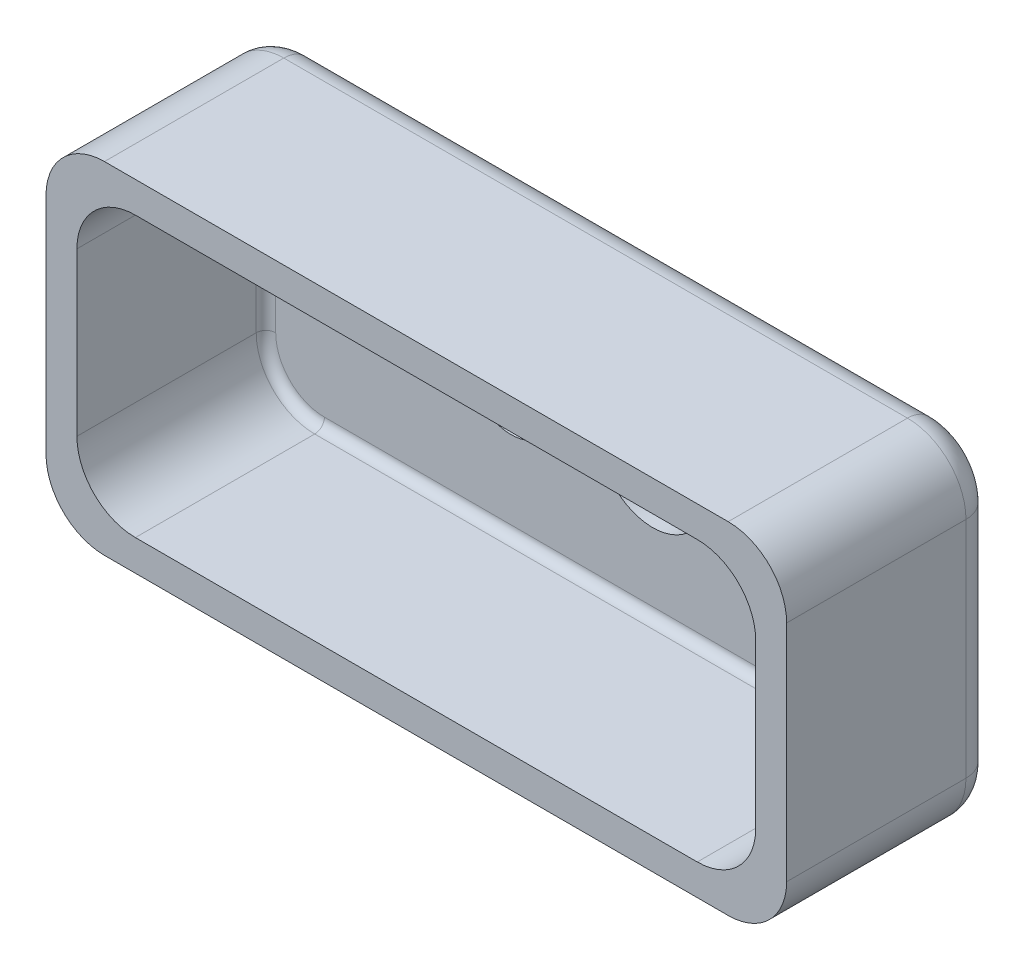
from build123d import *

# Parameters (mm, degrees)
SKETCH1_W                = 760
SKETCH1_H                = 350
BOSS_EXTRUDE1_DEPTH      = 38
SKETCH2_R                = 65
SKETCH2_R_2              = 55
SKETCH2_R_3              = 45
CUT_EXTRUDE1_DEPTH       = 473.628796964
CUT_EXTRUDE3_DEPTH       = 473.628796964
SKETCH5_R                = 75
SKETCH5_R_2              = 3
SKETCH5_R_3              = 70
SKETCH5_R_4              = 40
CUT_EXTRUDE7_DEPTH       = 7
SKETCH7_R                = 3
CUT_EXTRUDE8_DEPTH       = 473.628796964
SKETCH8_W                = 760
SKETCH8_H                = 350
CUT_EXTRUDE9_DEPTH       = 18
SKETCH9_OUTSIDE_W        = 929.392
SKETCH9_OUTSIDE_H        = 519.392
CUT_EXTRUDE10_DEPTH      = 472.523042618
BOSS_EXTRUDE2_DEPTH      = 194
FILLET1_R                = 10
SKETCH12_R               = 40
SKETCH12_R_2             = 20
SKETCH12_R_3             = 3
BOSS_EXTRUDE4_DEPTH      = 7
BOSS_EXTRUDE4_DEPTH_BACK = 2
SKETCH13_R               = 3
BOSS_EXTRUDE8_DEPTH      = 20
SKETCH11_R               = 80
SKETCH11_R_2             = 3
CUT_EXTRUDE11_DEPTH      = 7
SKETCH15_R               = 3
CUT_EXTRUDE12_DEPTH      = 518.42630366
FILLET2_R                = 30


with BuildPart() as part:
    # Sketch1 → Boss-Extrude1 (new body)
    with BuildSketch(Plane.XY):
        with Locations((42.843137255, 32.696078431)):
            Rectangle(SKETCH1_W, SKETCH1_H)
    extrude(amount=BOSS_EXTRUDE1_DEPTH)

    # Sketch2 → Cut-Extrude1 (cut, through all)
    with BuildSketch(Plane.XY.offset(38)):
        with Locations((245.403137255, 24.656078431)):
            Circle(SKETCH2_R)
        with Locations((91.403137255, 24.656078431)):
            Circle(SKETCH2_R_2)
        with Locations((-54.006862745, 24.656078431)):
            Circle(SKETCH2_R_3)
    extrude(amount=-CUT_EXTRUDE1_DEPTH, mode=Mode.SUBTRACT)

    # Sketch3 → Cut-Extrude3 (cut, through all)
    with BuildSketch(Plane.XY.offset(38)):
        with BuildLine():
            ThreePointArc((-211.086862745, 24.656078431), (-191.086862745, 4.656078431), (-171.086862745, 24.656078431))
            Line((-171.086862745, 24.656078431), (-191.086862745, 24.656078431))
            Line((-191.086862745, 24.656078431), (-211.086862745, 24.656078431))
        make_face()
        with BuildLine():
            Line((-191.086862745, 24.656078431), (-171.086862745, 24.656078431))
            ThreePointArc((-171.086862745, 24.656078431), (-191.086862745, 44.656078431), (-211.086862745, 24.656078431))
            Line((-211.086862745, 24.656078431), (-191.086862745, 24.656078431))
        make_face()
    extrude(amount=-CUT_EXTRUDE3_DEPTH, mode=Mode.SUBTRACT)

    # Sketch5 → Cut-Extrude7 (cut)
    with BuildSketch(Plane(origin=(0, 0, 0), x_dir=(-1, 0, 0), z_dir=(0, 0, -1))):
        with Locations((54.006862745, 24.656078431)):
            Circle(SKETCH5_R)
        with Locations((54.006862745, 84.656078431)):
            Circle(SKETCH5_R_2, mode=Mode.SUBTRACT)
        with Locations((105.968386972, -5.343921569)):
            Circle(SKETCH5_R_2, mode=Mode.SUBTRACT)
        with Locations((2.045338518, -5.343921569)):
            Circle(SKETCH5_R_2, mode=Mode.SUBTRACT)
        with Locations((-91.403137255, 24.656078431)):
            Circle(SKETCH5_R_3)
        with Locations((-91.403137255, 84.656078431)):
            Circle(SKETCH5_R_2, mode=Mode.SUBTRACT)
        with Locations((-39.441613028, -5.343921569)):
            Circle(SKETCH5_R_2, mode=Mode.SUBTRACT)
        with Locations((-143.364661482, -5.343921569)):
            Circle(SKETCH5_R_2, mode=Mode.SUBTRACT)
        with Locations((191.086862745, 24.656078431)):
            Circle(SKETCH5_R_4)
        with Locations((191.086862745, 54.656078431)):
            Circle(SKETCH5_R_2, mode=Mode.SUBTRACT)
        with Locations((217.067624859, 9.656078431)):
            Circle(SKETCH5_R_2, mode=Mode.SUBTRACT)
        with Locations((165.106100632, 9.656078431)):
            Circle(SKETCH5_R_2, mode=Mode.SUBTRACT)
    extrude(amount=-CUT_EXTRUDE7_DEPTH, mode=Mode.SUBTRACT)

    # Sketch7 → Cut-Extrude8 (cut, through all)
    with BuildSketch(Plane(origin=(0, 0, 0), x_dir=(-1, 0, 0), z_dir=(0, 0, -1))):
        with Locations((-91.403137255, 84.656078431)):
            Circle(SKETCH7_R)
        with Locations((-143.364661482, -5.343921569)):
            Circle(SKETCH7_R)
        with Locations((-39.441613028, -5.343921569)):
            Circle(SKETCH7_R)
        with Locations((2.045338518, -5.343921569)):
            Circle(SKETCH7_R)
        with Locations((54.006862745, 84.656078431)):
            Circle(SKETCH7_R)
        with Locations((105.968386972, -5.343921569)):
            Circle(SKETCH7_R)
        with Locations((191.086862745, 54.656078431)):
            Circle(SKETCH7_R)
        with Locations((165.106100632, 9.656078431)):
            Circle(SKETCH7_R)
        with Locations((217.067624859, 9.656078431)):
            Circle(SKETCH7_R)
    extrude(amount=-CUT_EXTRUDE8_DEPTH, mode=Mode.SUBTRACT)

    # Sketch8 → Cut-Extrude9 (cut)
    with BuildSketch(Plane.XY.offset(38)):
        with Locations((42.843137255, 32.696078431)):
            Rectangle(SKETCH8_W, SKETCH8_H)
    extrude(amount=-CUT_EXTRUDE9_DEPTH, mode=Mode.SUBTRACT)

    # Sketch9 outside → Cut-Extrude10 (cut, through all)
    with BuildSketch(Plane.XY.offset(20)):
        with Locations((42.843, 32.696)):
            Rectangle(SKETCH9_OUTSIDE_W, SKETCH9_OUTSIDE_H)
        with BuildLine():
            Line((-277.156862745, 207.696078431), (362.843137255, 207.696078431))
            ThreePointArc((362.843137255, 207.696078431), (405.269544126, 190.122485303), (422.843137255, 147.696078431))
            Line((422.843137255, 147.696078431), (422.843137255, -82.303921569))
            ThreePointArc((422.843137255, -82.303921569), (405.269544126, -124.73032844), (362.843137255, -142.303921569))
            Line((362.843137255, -142.303921569), (-277.156862745, -142.303921569))
            ThreePointArc((-277.156862745, -142.303921569), (-319.583269616, -124.73032844), (-337.156862745, -82.303921569))
            Line((-337.156862745, -82.303921569), (-337.156862745, 147.696078431))
            ThreePointArc((-337.156862745, 147.696078431), (-319.583269616, 190.122485303), (-277.156862745, 207.696078431))
        make_face(mode=Mode.SUBTRACT)
    extrude(amount=-CUT_EXTRUDE10_DEPTH, mode=Mode.SUBTRACT)

    # Sketch10 → Boss-Extrude2 (add)
    with BuildSketch(Plane.XY.offset(20)):
        with BuildLine():
            Line((-277.156862745, 207.696078431), (362.843137255, 207.696078431))
            ThreePointArc((362.843137255, 207.696078431), (405.269544126, 190.122485303), (422.843137255, 147.696078431))
            Line((422.843137255, 147.696078431), (422.843137255, -82.303921569))
            ThreePointArc((422.843137255, -82.303921569), (405.269544126, -124.73032844), (362.843137255, -142.303921569))
            Line((362.843137255, -142.303921569), (-277.156862745, -142.303921569))
            ThreePointArc((-277.156862745, -142.303921569), (-319.583269616, -124.73032844), (-337.156862745, -82.303921569))
            Line((-337.156862745, -82.303921569), (-337.156862745, 147.696078431))
            ThreePointArc((-337.156862745, 147.696078431), (-319.583269616, 190.122485303), (-277.156862745, 207.696078431))
        make_face()
        with BuildLine():
            Line((-245.441133993, 175.980349679), (331.127408502, 175.980349679))
            ThreePointArc((331.127408502, 175.980349679), (373.553815374, 158.40675655), (391.127408502, 115.980349679))
            Line((391.127408502, 115.980349679), (391.127408502, -50.588192816))
            ThreePointArc((391.127408502, -50.588192816), (373.553815374, -93.014599687), (331.127408502, -110.588192816))
            Line((331.127408502, -110.588192816), (-245.441133993, -110.588192816))
            ThreePointArc((-245.441133993, -110.588192816), (-287.867540864, -93.014599687), (-305.441133993, -50.588192816))
            Line((-305.441133993, -50.588192816), (-305.441133993, 115.980349679))
            ThreePointArc((-305.441133993, 115.980349679), (-287.867540864, 158.40675655), (-245.441133993, 175.980349679))
        make_face(mode=Mode.SUBTRACT)
    extrude(amount=BOSS_EXTRUDE2_DEPTH)

    # Fillet1
    fillet1_edges = [part.edges().sort_by_distance(p)[0] for p in [
        (-287.867540864, -93.014599687, 20),
        (42.843137255, -110.588192816, 20),
        (373.553815374, -93.014599687, 20),
        (391.127408502, 32.696078431, 20),
        (373.553815374, 158.40675655, 20),
        (42.843137255, 175.980349679, 20),
        (-287.867540864, 158.40675655, 20),
        (-305.441133993, 32.696078431, 20),
    ]]
    fillet(fillet1_edges, radius=FILLET1_R)

    # Sketch12 → Boss-Extrude4 (add, two sides)
    with BuildSketch(Plane(origin=(0, 0, 7), x_dir=(-1, 0, 0), z_dir=(0, 0, -1))) as boss_extrude4_sk:
        with Locations((191.086862745, 24.656078431)):
            Circle(SKETCH12_R)
        with Locations(Location((191.086862745, 24.656078431, 0), (0, 0, 180))):
            Circle(SKETCH12_R_2, mode=Mode.SUBTRACT)
        with Locations((191.086862745, 54.656078431)):
            Circle(SKETCH12_R_3, mode=Mode.SUBTRACT)
        with Locations((165.106100632, 9.656078431)):
            Circle(SKETCH12_R_3, mode=Mode.SUBTRACT)
        with Locations((217.067624859, 9.656078431)):
            Circle(SKETCH12_R_3, mode=Mode.SUBTRACT)
    extrude(amount=BOSS_EXTRUDE4_DEPTH)
    extrude(boss_extrude4_sk.sketch, amount=-BOSS_EXTRUDE4_DEPTH_BACK)

    # Sketch13 → Boss-Extrude8 (add)
    with BuildSketch(Plane(origin=(0, 0, 0), x_dir=(-1, 0, 0), z_dir=(0, 0, -1))):
        with Locations((191.086862745, 54.656078431)):
            Circle(SKETCH13_R)
        with Locations((217.067624859, 9.656078431)):
            Circle(SKETCH13_R)
        with Locations((165.106100632, 9.656078431)):
            Circle(SKETCH13_R)
    extrude(amount=-BOSS_EXTRUDE8_DEPTH)

    # Sketch11 → Cut-Extrude11 (cut)
    with BuildSketch(Plane(origin=(0, 0, 0), x_dir=(-1, 0, 0), z_dir=(0, 0, -1))):
        with Locations((-245.403137255, 24.656078431)):
            Circle(SKETCH11_R)
        with Locations((-245.403137255, 94.656078431)):
            Circle(SKETCH11_R_2, mode=Mode.SUBTRACT)
        with Locations((-184.78135899, -10.343921569)):
            Circle(SKETCH11_R_2, mode=Mode.SUBTRACT)
        with Locations((-306.02491552, -10.343921569)):
            Circle(SKETCH11_R_2, mode=Mode.SUBTRACT)
    extrude(amount=-CUT_EXTRUDE11_DEPTH, mode=Mode.SUBTRACT)

    # Sketch15 → Cut-Extrude12 (cut, through all)
    with BuildSketch(Plane(origin=(0, 0, 0), x_dir=(-1, 0, 0), z_dir=(0, 0, -1))):
        with Locations((-245.403137255, 94.656078431)):
            Circle(SKETCH15_R)
        with Locations((-306.02491552, -10.343921569)):
            Circle(SKETCH15_R)
        with Locations((-184.78135899, -10.343921569)):
            Circle(SKETCH15_R)
    extrude(amount=-CUT_EXTRUDE12_DEPTH, mode=Mode.SUBTRACT)

    # Fillet2
    fillet2_edges = [part.edges().sort_by_distance(p)[0] for p in [
        (-337.156862745, 32.696078431, 0),
        (42.843137255, 207.696078431, 0),
        (422.843137255, 32.696078431, 0),
        (42.843137255, -142.303921569, 0),
        (-319.583269616, -124.73032844, 0),
        (405.269544126, -124.73032844, 0),
        (405.269544126, 190.122485303, 0),
        (-319.583269616, 190.122485303, 0),
    ]]
    fillet(fillet2_edges, radius=FILLET2_R)


solid = part.part
